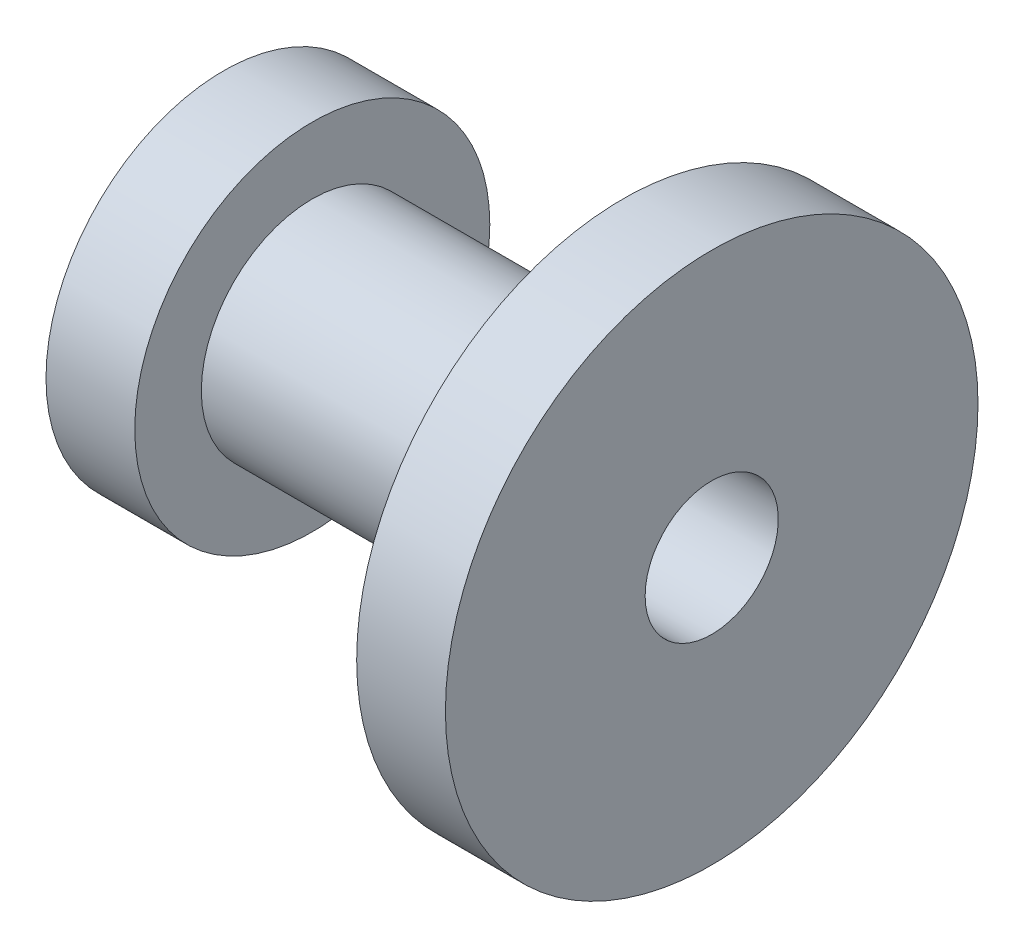
from build123d import *

# Parameters (mm, degrees)
SKETCH_3_R          = 15
CUT_EXTRUDE_1_DEPTH = 227


with BuildPart() as part:
    # 스케치2 → 회전1 (revolve)
    with BuildSketch(Plane.XY):
        Polygon((0, 0), (0, 40), (20, 40), (20, 25), (90, 25), (90, 60), (110, 60), (110, 0), align=None)
    revolve(axis=Axis((0, 0, 0), (1, 0, 0)))

    # 스케치3 → 컷-돌출1 (cut)
    with BuildSketch(Plane.ZY):
        Circle(SKETCH_3_R)
    extrude(amount=-CUT_EXTRUDE_1_DEPTH, mode=Mode.SUBTRACT)


solid = part.part
